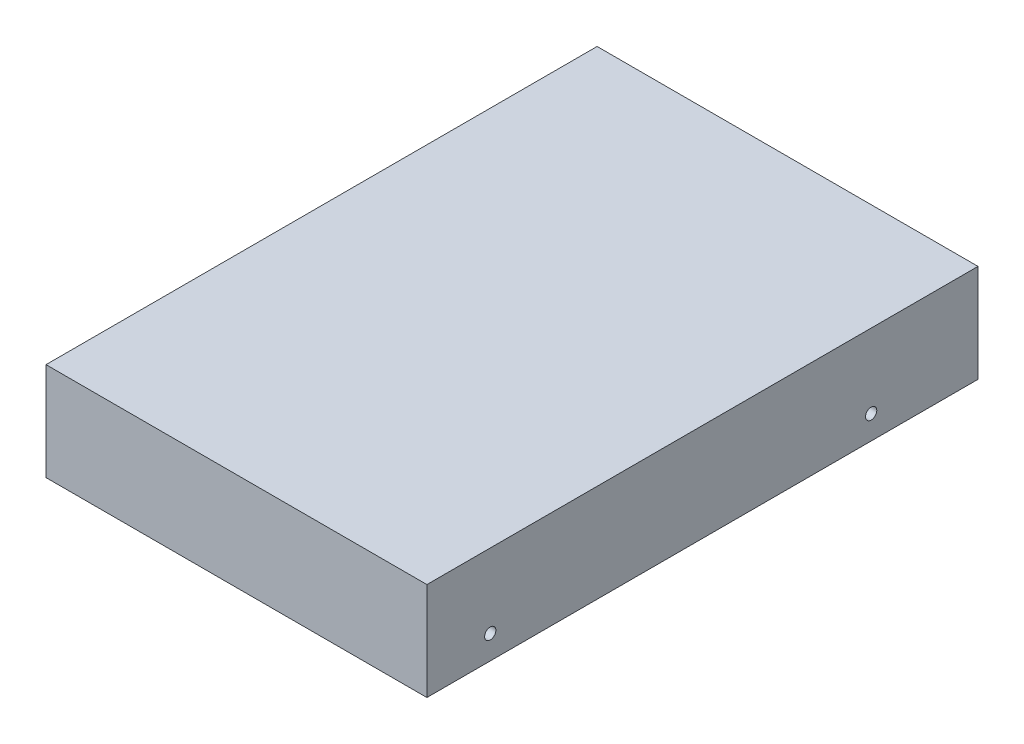
from build123d import *

# Parameters (mm, degrees)
SKETCH1_W           = 101.6
SKETCH1_H           = 147
BOSS_EXTRUDE1_DEPTH = 26.1
SKETCH2_R           = 1.7526
BOSS_EXTRUDE2_DEPTH = 3.175
SKETCH2_2_R         = 1.7526
CUT_EXTRUDE2_DEPTH  = 3
SKETCH4_R           = 1.5
CUT_EXTRUDE3_DEPTH  = 3


with BuildPart() as part:
    # Sketch1 → Boss-Extrude1 (new body)
    with BuildSketch(Plane(origin=(0, 0, 0), x_dir=(1, 0, 0), z_dir=(0, 1, 0))):
        with Locations((50.8, 73.5)):
            Rectangle(SKETCH1_W, SKETCH1_H)
    extrude(amount=BOSS_EXTRUDE1_DEPTH)

    # Sketch2 → Boss-Extrude2 (add)
    with BuildSketch(Plane(origin=(0, 0, 0), x_dir=(0, 0, -1), z_dir=(1, 0, 0))):
        with Locations((16.9, 6.35)):
            Circle(SKETCH2_R)
        with Locations((118.5, 6.35)):
            Circle(SKETCH2_R)
    extrude(amount=BOSS_EXTRUDE2_DEPTH)

    # Sketch2_2 → Cut-Extrude2 (cut)
    with BuildSketch(Plane(origin=(0, 0, 0), x_dir=(0, 0, -1), z_dir=(1, 0, 0))):
        with Locations((16.9, 6.35)):
            Circle(SKETCH2_2_R)
        with Locations((118.5, 6.35)):
            Circle(SKETCH2_2_R)
    extrude(amount=CUT_EXTRUDE2_DEPTH, mode=Mode.SUBTRACT)

    # Sketch4 → Cut-Extrude3 (cut)
    with BuildSketch(Plane(origin=(101.6, 0, 0), x_dir=(0, 0, -1), z_dir=(1, 0, 0))):
        with Locations((118.5, 6.35)):
            Circle(SKETCH4_R)
        with Locations((16.9, 6.35)):
            Circle(SKETCH4_R)
    extrude(amount=-CUT_EXTRUDE3_DEPTH, mode=Mode.SUBTRACT)


solid = part.part
